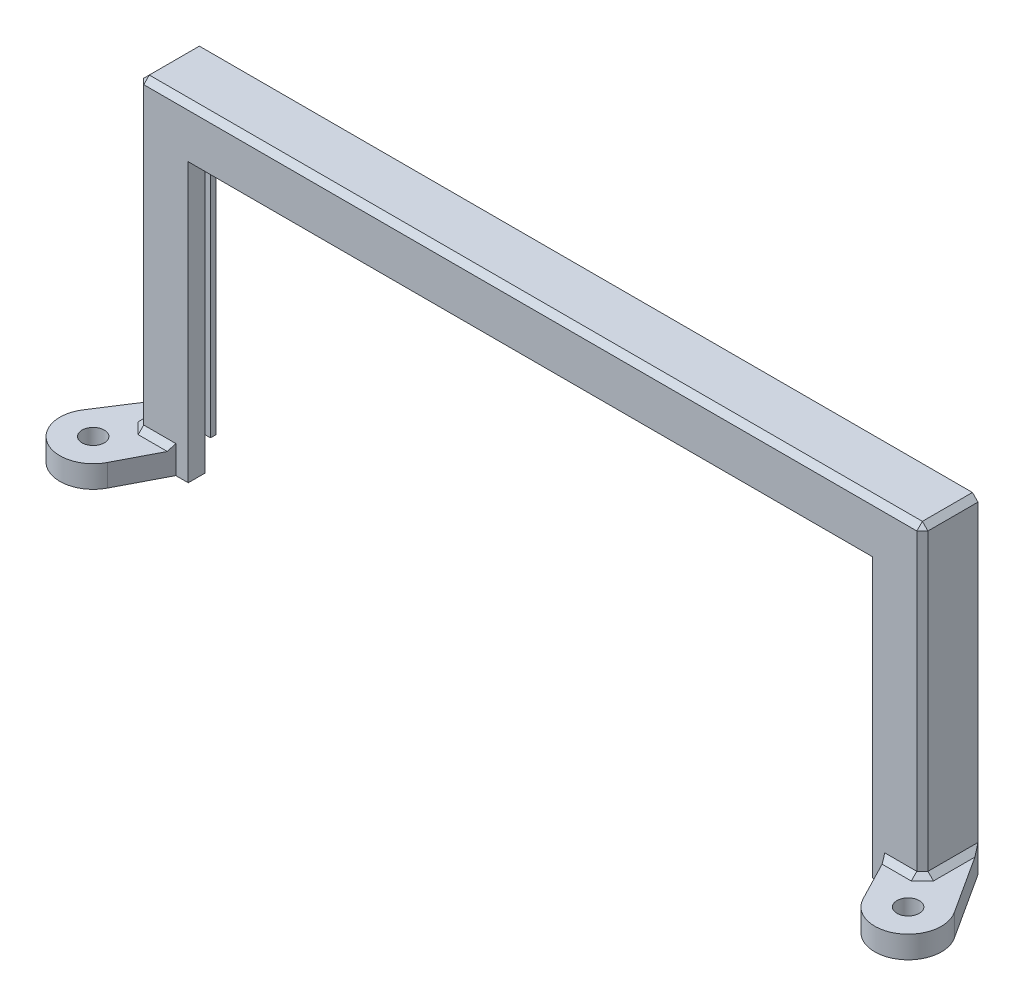
from build123d import *

# Parameters (mm, degrees)
SKETCH1_W           = 141
SKETCH1_H           = 59
BOSS_EXTRUDE1_DEPTH = 10
SKETCH2_W           = 133
SKETCH2_H           = 55
CUT_EXTRUDE1_DEPTH  = 7
SKETCH3_W           = 123
SKETCH3_H           = 50
CUT_EXTRUDE2_DEPTH  = 7
SKETCH4_W           = 1.5
SKETCH4_H           = 4
CUT_EXTRUDE3_DEPTH  = 55
SKETCH5_R           = 2
BOSS_EXTRUDE2_DEPTH = 4
CHAMFER1_SIZE       = 1


with BuildPart() as part:
    # Sketch1 → Boss-Extrude1 (new body)
    with BuildSketch(Plane.XY):
        with Locations((70.5, 29.5)):
            Rectangle(SKETCH1_W, SKETCH1_H)
    extrude(amount=BOSS_EXTRUDE1_DEPTH)

    # Sketch2 → Cut-Extrude1 (cut)
    with BuildSketch(Plane(origin=(0, 0, 0), x_dir=(-1, 0, 0), z_dir=(0, 0, -1))):
        with Locations((-70.5, 27.5)):
            Rectangle(SKETCH2_W, SKETCH2_H)
    extrude(amount=-CUT_EXTRUDE1_DEPTH, mode=Mode.SUBTRACT)

    # Sketch3 → Cut-Extrude2 (cut)
    with BuildSketch(Plane(origin=(0, 0, 7), x_dir=(-1, 0, 0), z_dir=(0, 0, -1))):
        with Locations((-70.5, 25)):
            Rectangle(SKETCH3_W, SKETCH3_H)
    extrude(amount=-CUT_EXTRUDE2_DEPTH, mode=Mode.SUBTRACT)

    # Sketch4 → Cut-Extrude3 (cut)
    with BuildSketch(Plane(origin=(0, 0, 0), x_dir=(-1, 0, 0), z_dir=(0, -1, 0))):
        with Locations((-3.25, -3)):
            Rectangle(SKETCH4_W, SKETCH4_H)
        with Locations((-137.75, -3)):
            Rectangle(SKETCH4_W, SKETCH4_H)
    extrude(amount=-CUT_EXTRUDE3_DEPTH, mode=Mode.SUBTRACT)

    # Sketch5 → Boss-Extrude2 (add)
    with BuildSketch(Plane(origin=(0, 0, 0), x_dir=(-1, 0, 0), z_dir=(0, -1, 0))):
        with BuildLine():
            Line((-2.565492231, -18.088154896), (-6.758248996, -10))
            Line((-6.758248996, -10), (0, -10))
            Line((0, -10), (0, 0))
            Line((0, 0), (7.800562775, -12.070115644))
            ThreePointArc((7.800562775, -12.070115644), (5.773784886, -20.515765997), (-2.565492231, -18.088154896))
        make_face()
        with Locations((2.761331332, -15.326823563)):
            Circle(SKETCH5_R, mode=Mode.SUBTRACT)
        with BuildLine():
            Line((-141, -10), (-134.241751004, -10))
            Line((-134.241751004, -10), (-138.434507769, -18.088154896))
            ThreePointArc((-138.434507769, -18.088154896), (-146.773784886, -20.515765997), (-148.800562775, -12.070115644))
            Line((-148.800562775, -12.070115644), (-141, 0))
            Line((-141, 0), (-141, -10))
        make_face()
        with Locations((-143.761331332, -15.326823563)):
            Circle(SKETCH5_R, mode=Mode.SUBTRACT)
    extrude(amount=-BOSS_EXTRUDE2_DEPTH)

    # Chamfer1
    chamfer1_edges = [part.edges().sort_by_distance(p)[0] for p in [
        (70.5, 59, 10),
        (0, 31.5, 10),
        (0, 59, 5),
        (141, 59, 5),
        (3.379124498, 4, 10),
        (0, 4, 5),
        (141, 31.5, 10),
        (141, 4, 5),
        (137.620875502, 4, 10),
    ]]
    chamfer(chamfer1_edges, length=CHAMFER1_SIZE)


solid = part.part
